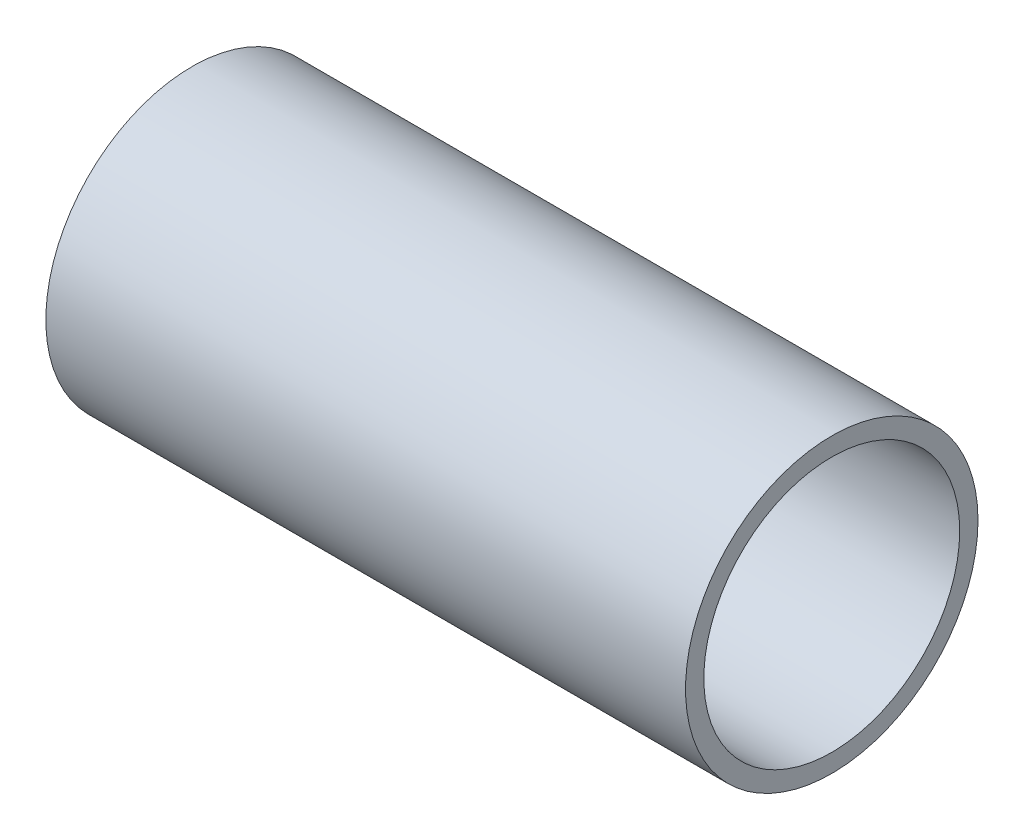
from build123d import *

# Parameters (mm, degrees)
SKETCH1_R           = 14.5161
SKETCH1_R_2         = 12.7
BOSS_EXTRUDE1_DEPTH = 31.75


with BuildPart() as part:
    # Sketch1 → Boss-Extrude1 (new body, symmetric)
    with BuildSketch(Plane(origin=(0, 0, 0), x_dir=(0, 0, -1), z_dir=(1, 0, 0))):
        Circle(SKETCH1_R)
        Circle(SKETCH1_R_2, mode=Mode.SUBTRACT)
    extrude(amount=BOSS_EXTRUDE1_DEPTH, both=True)


solid = part.part
